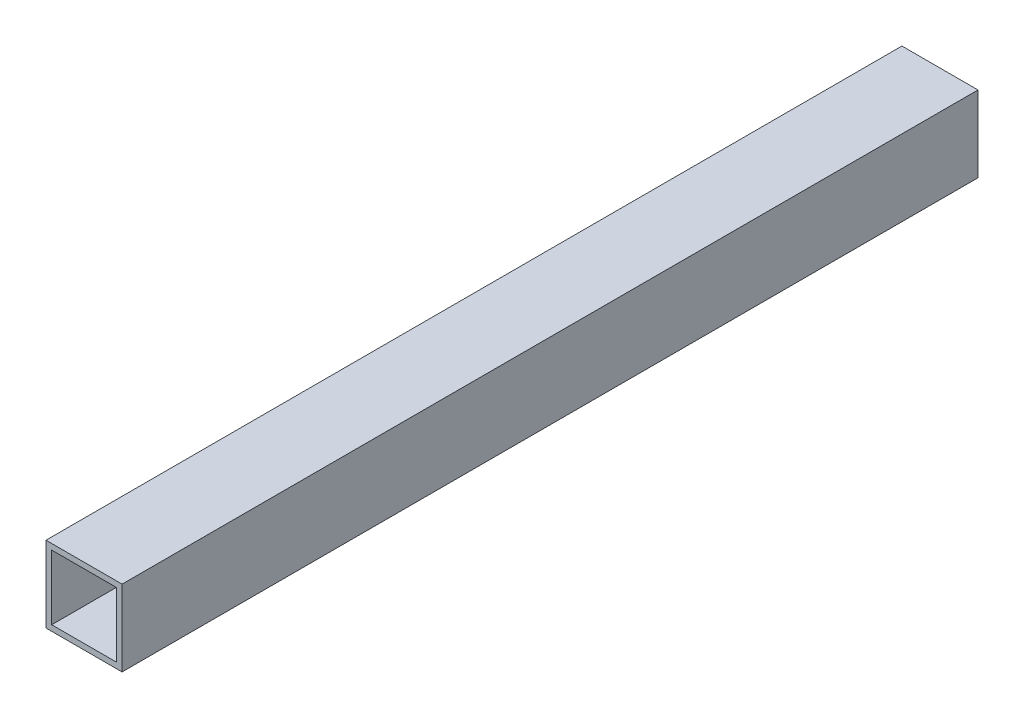
from build123d import *

# Parameters (mm, degrees)
SKETCH1_W           = 40
SKETCH1_H           = 40
SKETCH1_W_2         = 34
SKETCH1_H_2         = 34
BOSS_EXTRUDE1_DEPTH = 450


with BuildPart() as part:
    # Sketch1 → Boss-Extrude1 (new body)
    with BuildSketch(Plane.XY):
        Rectangle(SKETCH1_W, SKETCH1_H)
        Rectangle(SKETCH1_W_2, SKETCH1_H_2, mode=Mode.SUBTRACT)
    extrude(amount=BOSS_EXTRUDE1_DEPTH)


solid = part.part
